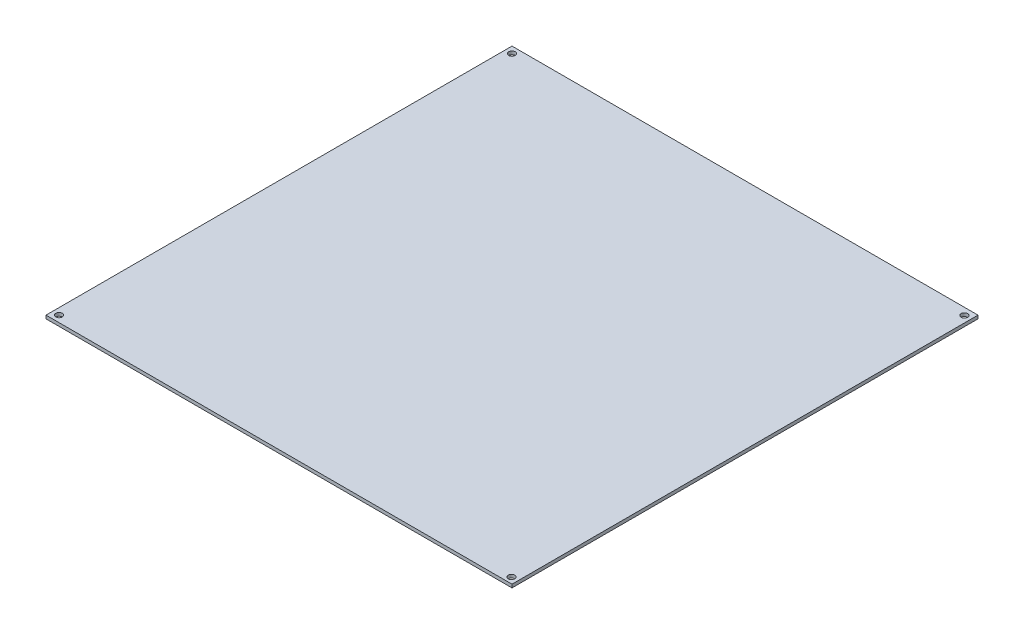
from build123d import *

# Parameters (mm, degrees)
CROQUIS1_W              = 214
CROQUIS1_H              = 214
CROQUIS1_R              = 1.5
SALIENTE_EXTRUIR2_DEPTH = 1.5


with BuildPart() as part:
    # Croquis1 → Saliente-Extruir2 (new body)
    with BuildSketch(Plane(origin=(0, 0, 0), x_dir=(1, 0, 0), z_dir=(0, 1, 0))):
        with Locations((-18.043137255, -45.317647059)):
            Rectangle(CROQUIS1_W, CROQUIS1_H)
        with Locations((-122.042987014, 58.682352941)):
            Circle(CROQUIS1_R, mode=Mode.SUBTRACT)
        with Locations((85.956862745, 58.432352941)):
            Circle(CROQUIS1_R, mode=Mode.SUBTRACT)
        with Locations((-122.042987014, -149.317647059)):
            Circle(CROQUIS1_R, mode=Mode.SUBTRACT)
        with Locations((85.956862745, -149.567647059)):
            Circle(CROQUIS1_R, mode=Mode.SUBTRACT)
    extrude(amount=SALIENTE_EXTRUIR2_DEPTH)


solid = part.part
